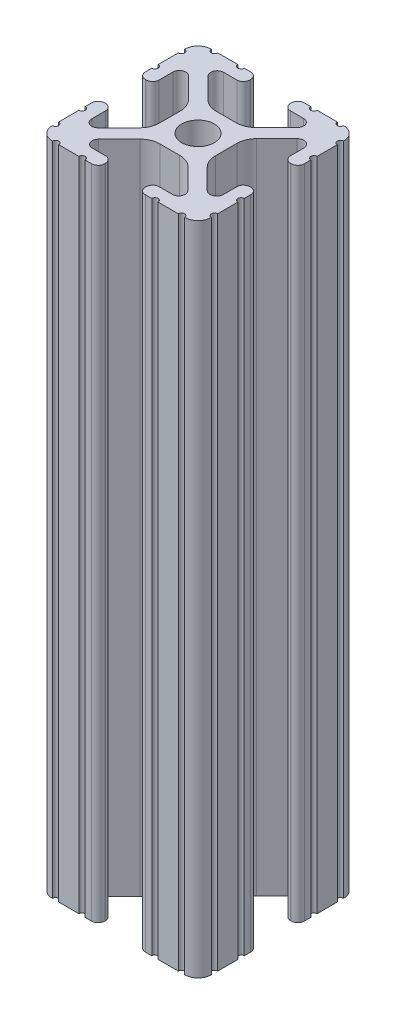
from build123d import *

# Parameters (mm, degrees)
SKETCH1_R           = 2.6035
BOSS_EXTRUDE1_DEPTH = 104.775


with BuildPart() as part:
    # Sketch1 → Boss-Extrude1 (new body)
    with BuildSketch(Plane(origin=(0, 0, 0), x_dir=(0, 0, -1), z_dir=(0, 1, 0))):
        with BuildLine():
            Line((6.333126718, -12.7), (9.550443118, -12.7))
            ThreePointArc((9.550443118, -12.7), (10.058366869, -12.192000006), (10.566443095, -12.699847501))
            ThreePointArc((10.566443095, -12.699847501), (12.082537762, -12.08250727), (12.699846982, -10.566399977))
            ThreePointArc((12.699846982, -10.566399977), (12.192000006, -10.058323491), (12.7, -9.5504))
            Line((12.7, -9.5504), (12.7, -6.3330836))
            ThreePointArc((12.7, -6.3330836), (12.192, -5.8250836), (12.7, -5.3170836))
            Line((12.7, -5.3170836), (12.7, -4.287469289))
            ThreePointArc((12.7, -4.287469289), (12.39275138, -3.545705502), (11.650987593, -3.238456882))
            Line((11.650987593, -3.238456882), (11.539212407, -3.238456882))
            ThreePointArc((11.539212407, -3.238456882), (10.79744862, -3.545705502), (10.4902, -4.287469289))
            Line((10.4902, -4.287469289), (10.4902, -6.402089023))
            ThreePointArc((10.4902, -6.402089023), (9.856505071, -7.351067942), (8.737131347, -7.129408934))
            Line((8.737131347, -7.129408934), (5.441005833, -3.840816462))
            ThreePointArc((5.441005833, -3.840816462), (4.750877967, -2.809883091), (4.5085, -1.593185507))
            Line((4.5085, -1.593185507), (4.5085, 1.593185507))
            ThreePointArc((4.5085, 1.593185507), (4.750877967, 2.809883091), (5.441005833, 3.840816462))
            Line((5.441005833, 3.840816462), (8.737131347, 7.129408934))
            ThreePointArc((8.737131347, 7.129408934), (9.856505071, 7.351067942), (10.4902, 6.402089023))
            Line((10.4902, 6.402089023), (10.4902, 4.287469289))
            ThreePointArc((10.4902, 4.287469289), (10.79744862, 3.545705502), (11.539212407, 3.238456882))
            Line((11.539212407, 3.238456882), (11.650987593, 3.238456882))
            ThreePointArc((11.650987593, 3.238456882), (12.39275138, 3.545705502), (12.7, 4.287469289))
            Line((12.7, 4.287469289), (12.7, 5.3170836))
            ThreePointArc((12.7, 5.3170836), (12.192, 5.8250836), (12.7, 6.3330836))
            Line((12.7, 6.3330836), (12.7, 9.5504))
            ThreePointArc((12.7, 9.5504), (12.192000006, 10.058323491), (12.699846982, 10.566399977))
            ThreePointArc((12.699846982, 10.566399977), (12.082537762, 12.08250727), (10.566443095, 12.699847501))
            ThreePointArc((10.566443095, 12.699847501), (10.058366869, 12.192000006), (9.550443118, 12.7))
            Line((9.550443118, 12.7), (6.333126718, 12.7))
            ThreePointArc((6.333126718, 12.7), (5.825126718, 12.192), (5.317126718, 12.7))
            Line((5.317126718, 12.7), (4.287512407, 12.7))
            ThreePointArc((4.287512407, 12.7), (3.54574862, 12.39275138), (3.2385, 11.650987593))
            Line((3.2385, 11.650987593), (3.2385, 11.539212407))
            ThreePointArc((3.2385, 11.539212407), (3.54574862, 10.79744862), (4.287512407, 10.4902))
            Line((4.287512407, 10.4902), (6.476788598, 10.4902))
            ThreePointArc((6.476788598, 10.4902), (7.432222385, 9.85140422), (7.207036008, 8.724370562))
            Line((7.207036008, 8.724370562), (3.898272566, 5.423169045))
            ThreePointArc((3.898272566, 5.423169045), (2.869120213, 4.736787962), (1.655778399, 4.4958))
            Line((1.655778399, 4.4958), (-1.655778399, 4.4958))
            ThreePointArc((-1.655778399, 4.4958), (-2.869120213, 4.736787962), (-3.898272566, 5.423169045))
            Line((-3.898272566, 5.423169045), (-7.207036008, 8.724370562))
            ThreePointArc((-7.207036008, 8.724370562), (-7.432222385, 9.85140422), (-6.476788598, 10.4902))
            Line((-6.476788598, 10.4902), (-4.287512407, 10.4902))
            ThreePointArc((-4.287512407, 10.4902), (-3.54574862, 10.79744862), (-3.2385, 11.539212407))
            Line((-3.2385, 11.539212407), (-3.2385, 11.650987593))
            ThreePointArc((-3.2385, 11.650987593), (-3.54574862, 12.39275138), (-4.287512407, 12.7))
            Line((-4.287512407, 12.7), (-5.317126718, 12.7))
            ThreePointArc((-5.317126718, 12.7), (-5.825126718, 12.192), (-6.333126718, 12.7))
            Line((-6.333126718, 12.7), (-9.550443118, 12.7))
            ThreePointArc((-9.550443118, 12.7), (-10.058366869, 12.192000006), (-10.566443095, 12.699847501))
            ThreePointArc((-10.566443095, 12.699847501), (-12.082537762, 12.08250727), (-12.699846982, 10.566399977))
            ThreePointArc((-12.699846982, 10.566399977), (-12.192000006, 10.058323491), (-12.7, 9.5504))
            Line((-12.7, 9.5504), (-12.7, 6.3330836))
            ThreePointArc((-12.7, 6.3330836), (-12.192, 5.8250836), (-12.7, 5.3170836))
            Line((-12.7, 5.3170836), (-12.7, 4.287469289))
            ThreePointArc((-12.7, 4.287469289), (-12.39275138, 3.545705502), (-11.650987593, 3.238456882))
            Line((-11.650987593, 3.238456882), (-11.539212407, 3.238456882))
            ThreePointArc((-11.539212407, 3.238456882), (-10.79744862, 3.545705502), (-10.4902, 4.287469289))
            Line((-10.4902, 4.287469289), (-10.4902, 6.402089023))
            ThreePointArc((-10.4902, 6.402089023), (-9.856505071, 7.351067942), (-8.737131347, 7.129408934))
            Line((-8.737131347, 7.129408934), (-5.441005833, 3.840816462))
            ThreePointArc((-5.441005833, 3.840816462), (-4.750877967, 2.809883091), (-4.5085, 1.593185507))
            Line((-4.5085, 1.593185507), (-4.5085, -1.593185507))
            ThreePointArc((-4.5085, -1.593185507), (-4.750877967, -2.809883091), (-5.441005833, -3.840816462))
            Line((-5.441005833, -3.840816462), (-8.737131347, -7.129408934))
            ThreePointArc((-8.737131347, -7.129408934), (-9.856505071, -7.351067942), (-10.4902, -6.402089023))
            Line((-10.4902, -6.402089023), (-10.4902, -4.287469289))
            ThreePointArc((-10.4902, -4.287469289), (-10.79744862, -3.545705502), (-11.539212407, -3.238456882))
            Line((-11.539212407, -3.238456882), (-11.650987593, -3.238456882))
            ThreePointArc((-11.650987593, -3.238456882), (-12.39275138, -3.545705502), (-12.7, -4.287469289))
            Line((-12.7, -4.287469289), (-12.7, -5.3170836))
            ThreePointArc((-12.7, -5.3170836), (-12.192, -5.8250836), (-12.7, -6.3330836))
            Line((-12.7, -6.3330836), (-12.7, -9.5504))
            ThreePointArc((-12.7, -9.5504), (-12.192000006, -10.058323491), (-12.699846982, -10.566399977))
            ThreePointArc((-12.699846982, -10.566399977), (-12.082537762, -12.08250727), (-10.566443095, -12.699847501))
            ThreePointArc((-10.566443095, -12.699847501), (-10.058366869, -12.192000006), (-9.550443118, -12.7))
            Line((-9.550443118, -12.7), (-6.333126718, -12.7))
            ThreePointArc((-6.333126718, -12.7), (-5.825126718, -12.192), (-5.317126718, -12.7))
            Line((-5.317126718, -12.7), (-4.287512407, -12.7))
            ThreePointArc((-4.287512407, -12.7), (-3.54574862, -12.39275138), (-3.2385, -11.650987593))
            Line((-3.2385, -11.650987593), (-3.2385, -11.539212407))
            ThreePointArc((-3.2385, -11.539212407), (-3.54574862, -10.79744862), (-4.287512407, -10.4902))
            Line((-4.287512407, -10.4902), (-6.416408329, -10.4902))
            ThreePointArc((-6.416408329, -10.4902), (-7.41473083, -9.822813117), (-7.179650497, -8.645192506))
            Line((-7.179650497, -8.645192506), (-3.952270251, -5.423690499))
            ThreePointArc((-3.952270251, -5.423690499), (-2.922936451, -4.736929036), (-1.709253557, -4.4958))
            Line((-1.709253557, -4.4958), (1.709253557, -4.4958))
            ThreePointArc((1.709253557, -4.4958), (2.922936451, -4.736929036), (3.952270251, -5.423690499))
            Line((3.952270251, -5.423690499), (7.179650497, -8.645192506))
            ThreePointArc((7.179650497, -8.645192506), (7.41473083, -9.822813117), (6.416408329, -10.4902))
            Line((6.416408329, -10.4902), (4.287512407, -10.4902))
            ThreePointArc((4.287512407, -10.4902), (3.54574862, -10.79744862), (3.2385, -11.539212407))
            Line((3.2385, -11.539212407), (3.2385, -11.650987593))
            ThreePointArc((3.2385, -11.650987593), (3.54574862, -12.39275138), (4.287512407, -12.7))
            Line((4.287512407, -12.7), (5.317126718, -12.7))
            ThreePointArc((5.317126718, -12.7), (5.825126718, -12.192), (6.333126718, -12.7))
        make_face()
        Circle(SKETCH1_R, mode=Mode.SUBTRACT)
    extrude(amount=BOSS_EXTRUDE1_DEPTH)


solid = part.part
